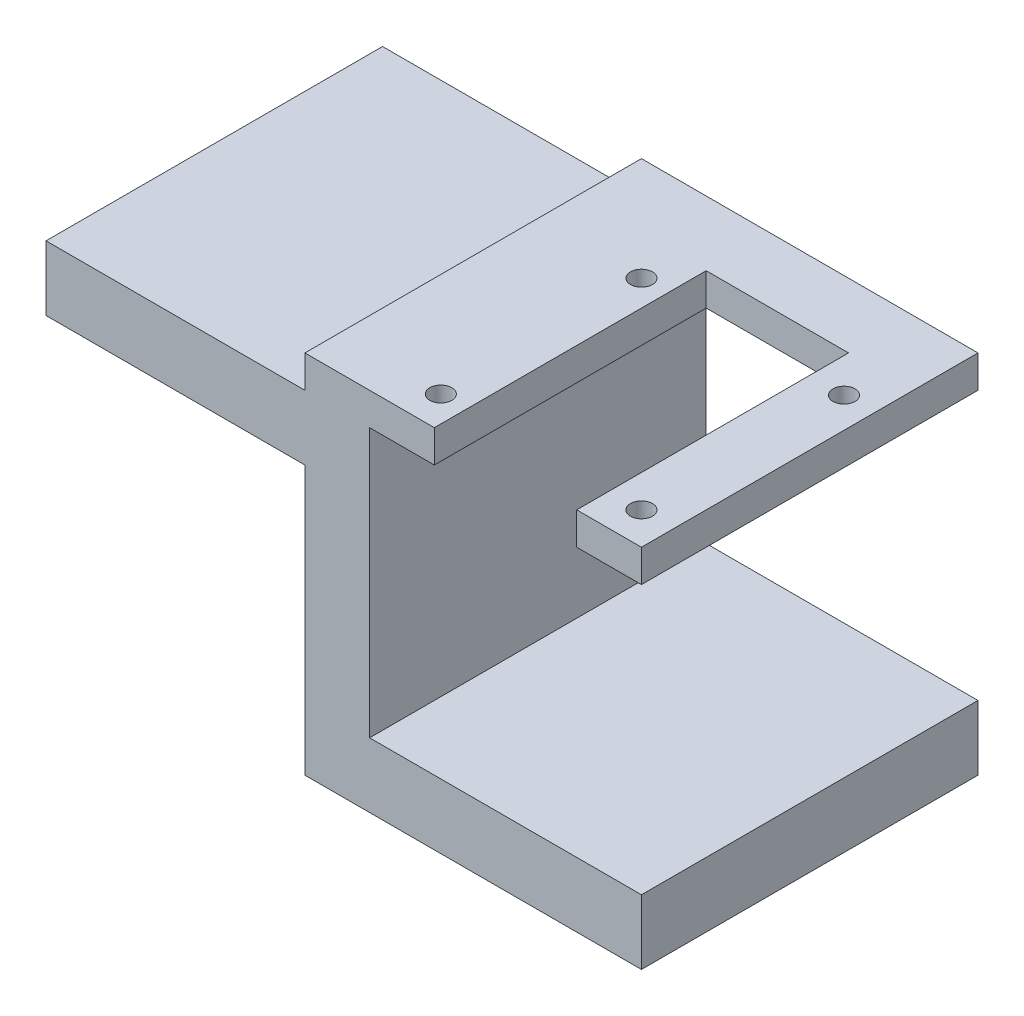
from build123d import *

# Parameters (mm, degrees)
SKETCH7_W             = 40
SKETCH7_H             = 25
SKETCH7_R             = 2.7
BOSS_EXTRUDE5_DEPTH   = 10
SKETCH7_W_2           = 22
SKETCH7_H_2           = 5
BOSS_EXTRUDE5_2_DEPTH = 10
SKETCH7_4_W           = 10
SKETCH7_4_H           = 5
BOSS_EXTRUDE6_DEPTH   = 52
CUT_EXTRUDE3_REACH    = 102.605
SKETCH8_R             = 1.7


with BuildPart() as part:
    # Sketch7 → Boss-Extrude5 (new body)
    with BuildSketch(Plane.XY):
        with Locations((-45, -22.5)):
            Rectangle(SKETCH7_W, SKETCH7_H)
        with Locations((-55, -22.5)):
            Circle(SKETCH7_R, mode=Mode.SUBTRACT)
        with Locations((-35, -22.5)):
            Circle(SKETCH7_R, mode=Mode.SUBTRACT)
    extrude(amount=BOSS_EXTRUDE5_DEPTH)



with BuildPart() as body_2:
    # Sketch7 → Boss-Extrude5 2 (new body)
    with BuildSketch(Plane.XY):
        with Locations((6, 2.5)):
            Rectangle(SKETCH7_W_2, SKETCH7_H_2)
    extrude(amount=BOSS_EXTRUDE5_2_DEPTH)


with BuildPart() as part_1:
    add(part.part)

    add(body_2.part)  # Boss-Extrude6 merges body 2
    # Sketch7_4 → Boss-Extrude6 (add)
    with BuildSketch(Plane.XY):
        Polygon((-15, -41.501763528), (-15, 0), (-5, 0), (-5, 5), (-25, 5), (-25, 0), (-65, 0), (-65, -10), (-25, -10), (-25, -51.501763528), (27, -51.501763528), (27, -41.501763528), align=None)
        with Locations((22, 2.5)):
            Rectangle(SKETCH7_4_W, SKETCH7_4_H)
    extrude(amount=BOSS_EXTRUDE6_DEPTH)

    # Sketch8 → Cut-Extrude3 (cut, up to next)
    with BuildSketch(Plane(origin=(0, 5, 0), x_dir=(1, 0, 0), z_dir=(0, 1, 0)), mode=Mode.PRIVATE) as cut_extrude3_sk1:
        with Locations((22, -47)):
            Circle(SKETCH8_R)
    cut_extrude3_tool1 = extrude(cut_extrude3_sk1.sketch, amount=-CUT_EXTRUDE3_REACH, mode=Mode.PRIVATE) & part_1.part
    # Sketch8 → Cut-Extrude3 (cut, up to next)
    with BuildSketch(Plane(origin=(0, 5, 0), x_dir=(1, 0, 0), z_dir=(0, 1, 0)), mode=Mode.PRIVATE) as cut_extrude3_sk2:
        with Locations((22.296850592, -16)):
            Circle(SKETCH8_R)
    cut_extrude3_tool2 = extrude(cut_extrude3_sk2.sketch, amount=-CUT_EXTRUDE3_REACH, mode=Mode.PRIVATE) & part_1.part
    # Sketch8 → Cut-Extrude3 (cut, up to next)
    with BuildSketch(Plane(origin=(0, 5, 0), x_dir=(1, 0, 0), z_dir=(0, 1, 0)), mode=Mode.PRIVATE) as cut_extrude3_sk3:
        with Locations((-9, -47)):
            Circle(SKETCH8_R)
    cut_extrude3_tool3 = extrude(cut_extrude3_sk3.sketch, amount=-CUT_EXTRUDE3_REACH, mode=Mode.PRIVATE) & part_1.part
    # Sketch8 → Cut-Extrude3 (cut, up to next)
    with BuildSketch(Plane(origin=(0, 5, 0), x_dir=(1, 0, 0), z_dir=(0, 1, 0)), mode=Mode.PRIVATE) as cut_extrude3_sk4:
        with Locations((-9, -16)):
            Circle(SKETCH8_R)
    cut_extrude3_tool4 = extrude(cut_extrude3_sk4.sketch, amount=-CUT_EXTRUDE3_REACH, mode=Mode.PRIVATE) & part_1.part
    add(cut_extrude3_tool1.solids().sort_by_distance((22, 5, 47))[0], mode=Mode.SUBTRACT)
    add(cut_extrude3_tool2.solids().sort_by_distance((22.296851, 5, 16))[0], mode=Mode.SUBTRACT)
    add(cut_extrude3_tool3.solids().sort_by_distance((-9, 5, 47))[0], mode=Mode.SUBTRACT)
    add(cut_extrude3_tool4.solids().sort_by_distance((-9, 5, 16))[0], mode=Mode.SUBTRACT)


solid = part_1.part
